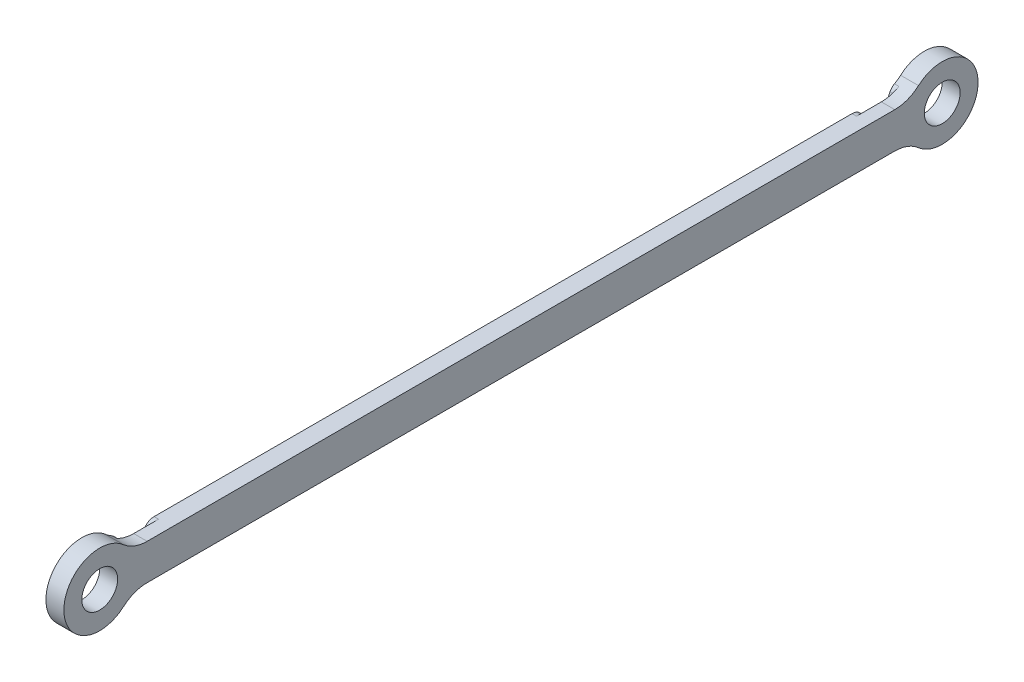
from build123d import *

# Parameters (mm, degrees)
SKETCH1_R           = 3.175
BOSS_EXTRUDE1_DEPTH = 1.5875
FILLET1_R           = 6.35
CUT_EXTRUDE1_DEPTH  = 0.79375
FILLET2_R           = 2


with BuildPart() as part:
    # Sketch1 → Boss-Extrude1 (new body, symmetric)
    with BuildSketch(Plane(origin=(0, 0, 0), x_dir=(0, 0, -1), z_dir=(1, 0, 0))):
        with BuildLine():
            ThreePointArc((5.499261314, 3.175), (-6.35, 0), (5.499261314, -3.175))
            Line((5.499261314, -3.175), (143.725738686, -3.175))
            ThreePointArc((143.725738686, -3.175), (155.575, 0), (143.725738686, 3.175))
            Line((143.725738686, 3.175), (5.499261314, 3.175))
        make_face()
        Circle(SKETCH1_R, mode=Mode.SUBTRACT)
        with Locations((149.225, 0)):
            Circle(SKETCH1_R, mode=Mode.SUBTRACT)
    extrude(amount=BOSS_EXTRUDE1_DEPTH, both=True)

    # Fillet1
    fillet1_edges = [part.edges().sort_by_distance(p)[0] for p in [
        (0, 3.175, -5.499261314),
        (0, 3.175, -143.725738686),
        (0, -3.175, -143.725738686),
        (0, -3.175, -5.499261314),
    ]]
    fillet(fillet1_edges, radius=FILLET1_R)

    # Sketch2 → Cut-Extrude1 (cut)
    with BuildSketch(Plane.ZY.offset(1.5875)):
        with BuildLine():
            Line((-10.383426303, -3.175), (-8.400260413, -3.175))
            ThreePointArc((-8.400260413, -3.175), (-7.035329576, -3.323430536), (-5.734208949, -3.761783052))
            ThreePointArc((-5.734208949, -3.761783052), (-6.858, 0), (-5.734208949, 3.761783052))
            ThreePointArc((-5.734208949, 3.761783052), (-7.035329576, 3.323430536), (-8.400260413, 3.175))
            Line((-8.400260413, 3.175), (-10.383426303, 3.175))
            ThreePointArc((-10.383426303, 3.175), (-10.858000128, 0), (-10.383426303, -3.175))
        make_face()
    cut_extrude1 = extrude(amount=-CUT_EXTRUDE1_DEPTH, mode=Mode.SUBTRACT)

    # Mirror1: Cut-Extrude1 across plane
    add(cut_extrude1.mirror(Plane.XY.offset(-74.6125)), mode=Mode.SUBTRACT)

    # Fillet2
    fillet2_edges = [part.edges().sort_by_distance(p)[0] for p in [
        (-1.190625, -3.175, -10.383426303),
        (-1.190625, 3.175, -10.383426303),
        (-1.190625, 3.761783052, -5.734208949),
        (-1.190625, -3.761783052, -5.734208949),
        (-1.190625, 3.175, -138.841573697),
        (-1.190625, -3.175, -138.841573697),
        (-1.190625, -3.761783052, -143.490791051),
        (-1.190625, 3.761783052, -143.490791051),
    ]]
    fillet(fillet2_edges, radius=FILLET2_R)


solid = part.part
